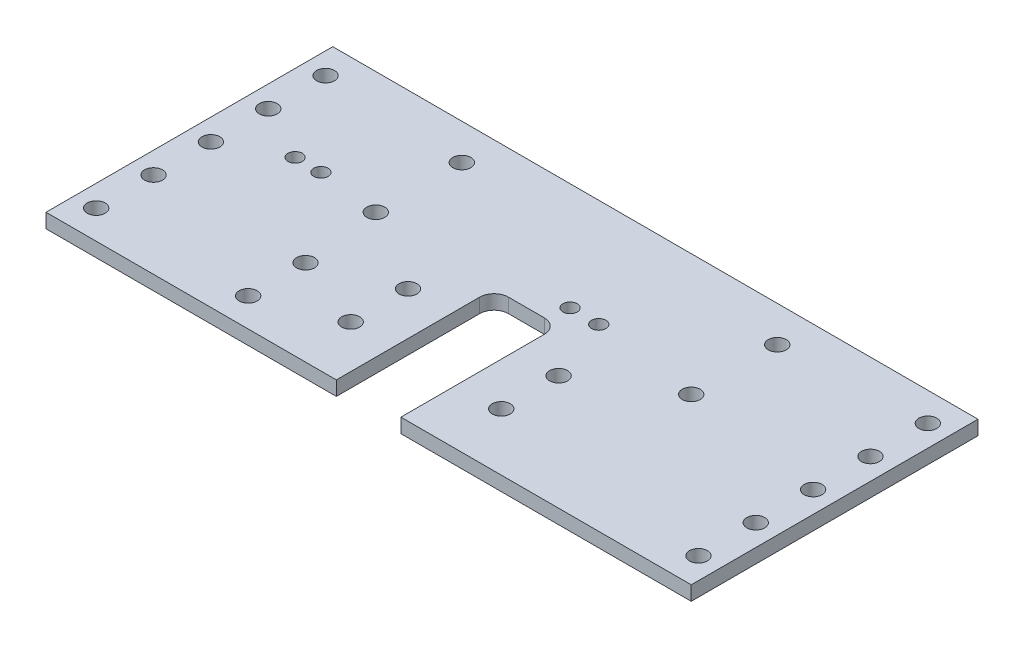
from build123d import *

# Parameters (mm, degrees)
SKETCH2_W            = 285.75
SKETCH2_H            = 6.35
STOCK_DEPTH          = 127
PEDAL_OPENINGS_DEPTH = 6.35
DRILLED_HOLES_REACH  = 8.35
SKETCH5_R            = 3.96875
SKETCH5_R_2          = 3.175


with BuildPart() as part:
    # Sketch2 → Stock (new body)
    with BuildSketch(Plane.XY):
        with Locations((-646.021194965, 51.468778461)):
            Rectangle(SKETCH2_W, SKETCH2_H)
    extrude(amount=-STOCK_DEPTH)

    # Sketch3 → Pedal Openings (cut)
    with BuildSketch(Plane(origin=(0, 54.643778461, 0), x_dir=(1, 0, 0), z_dir=(0, 1, 0))):
        with BuildLine():
            Line((-638.083694965, 69.85), (-653.958694965, 69.85))
            ThreePointArc((-653.958694965, 69.85), (-658.448823025, 67.990128061), (-660.308694965, 63.5))
            Line((-660.308694965, 63.5), (-660.308694965, 0))
            Line((-660.308694965, 0), (-631.733694965, 0))
            Line((-631.733694965, 0), (-631.733694965, 63.5))
            ThreePointArc((-631.733694965, 63.5), (-633.593566904, 67.990128061), (-638.083694965, 69.85))
        make_face()
    extrude(amount=-PEDAL_OPENINGS_DEPTH, mode=Mode.SUBTRACT)

    # Sketch5 → Drilled Holes (cut, up to next)
    with BuildSketch(Plane(origin=(0, 54.643778461, 0), x_dir=(1, 0, 0), z_dir=(0, 1, 0)), mode=Mode.PRIVATE) as drilled_holes_sk1:
        with Locations((-612.683694965, 25.4)):
            Circle(SKETCH5_R)
    drilled_holes_tool1 = extrude(drilled_holes_sk1.sketch, amount=-DRILLED_HOLES_REACH, mode=Mode.PRIVATE) & part.part
    add(drilled_holes_tool1.solids().sort_by_distance((-612.683695, 54.643778, -25.4))[0], mode=Mode.SUBTRACT)
    # Sketch5 → Drilled Holes (cut, up to next)
    with BuildSketch(Plane(origin=(0, 54.643778461, 0), x_dir=(1, 0, 0), z_dir=(0, 1, 0)), mode=Mode.PRIVATE) as drilled_holes_sk2:
        with Locations((-612.683694965, 50.8)):
            Circle(SKETCH5_R)
    drilled_holes_tool2 = extrude(drilled_holes_sk2.sketch, amount=-DRILLED_HOLES_REACH, mode=Mode.PRIVATE) & part.part
    add(drilled_holes_tool2.solids().sort_by_distance((-612.683695, 54.643778, -50.8))[0], mode=Mode.SUBTRACT)
    # Sketch5 → Drilled Holes (cut, up to next)
    with BuildSketch(Plane(origin=(0, 54.643778461, 0), x_dir=(1, 0, 0), z_dir=(0, 1, 0)), mode=Mode.PRIVATE) as drilled_holes_sk3:
        with Locations((-679.358694965, 50.8)):
            Circle(SKETCH5_R)
    drilled_holes_tool3 = extrude(drilled_holes_sk3.sketch, amount=-DRILLED_HOLES_REACH, mode=Mode.PRIVATE) & part.part
    add(drilled_holes_tool3.solids().sort_by_distance((-679.358695, 54.643778, -50.8))[0], mode=Mode.SUBTRACT)
    # Sketch5 → Drilled Holes (cut, up to next)
    with BuildSketch(Plane(origin=(0, 54.643778461, 0), x_dir=(1, 0, 0), z_dir=(0, 1, 0)), mode=Mode.PRIVATE) as drilled_holes_sk4:
        with Locations((-679.358694965, 25.4)):
            Circle(SKETCH5_R)
    drilled_holes_tool4 = extrude(drilled_holes_sk4.sketch, amount=-DRILLED_HOLES_REACH, mode=Mode.PRIVATE) & part.part
    add(drilled_holes_tool4.solids().sort_by_distance((-679.358695, 54.643778, -25.4))[0], mode=Mode.SUBTRACT)
    # Sketch5 → Drilled Holes (cut, up to next)
    with BuildSketch(Plane(origin=(0, 54.643778461, 0), x_dir=(1, 0, 0), z_dir=(0, 1, 0)), mode=Mode.PRIVATE) as drilled_holes_sk5:
        with Locations((-712.061194965, 12.7)):
            Circle(SKETCH5_R)
    drilled_holes_tool5 = extrude(drilled_holes_sk5.sketch, amount=-DRILLED_HOLES_REACH, mode=Mode.PRIVATE) & part.part
    add(drilled_holes_tool5.solids().sort_by_distance((-712.061195, 54.643778, -12.7))[0], mode=Mode.SUBTRACT)
    # Sketch5 → Drilled Holes (cut, up to next)
    with BuildSketch(Plane(origin=(0, 54.643778461, 0), x_dir=(1, 0, 0), z_dir=(0, 1, 0)), mode=Mode.PRIVATE) as drilled_holes_sk6:
        with Locations((-712.061194965, 38.1)):
            Circle(SKETCH5_R)
    drilled_holes_tool6 = extrude(drilled_holes_sk6.sketch, amount=-DRILLED_HOLES_REACH, mode=Mode.PRIVATE) & part.part
    add(drilled_holes_tool6.solids().sort_by_distance((-712.061195, 54.643778, -38.1))[0], mode=Mode.SUBTRACT)
    # Sketch5 → Drilled Holes (cut, up to next)
    with BuildSketch(Plane(origin=(0, 54.643778461, 0), x_dir=(1, 0, 0), z_dir=(0, 1, 0)), mode=Mode.PRIVATE) as drilled_holes_sk7:
        with Locations((-512.671194965, 12.7)):
            Circle(SKETCH5_R)
    drilled_holes_tool7 = extrude(drilled_holes_sk7.sketch, amount=-DRILLED_HOLES_REACH, mode=Mode.PRIVATE) & part.part
    add(drilled_holes_tool7.solids().sort_by_distance((-512.671195, 54.643778, -12.7))[0], mode=Mode.SUBTRACT)
    # Sketch5 → Drilled Holes (cut, up to next)
    with BuildSketch(Plane(origin=(0, 54.643778461, 0), x_dir=(1, 0, 0), z_dir=(0, 1, 0)), mode=Mode.PRIVATE) as drilled_holes_sk8:
        with Locations((-512.671194965, 38.1)):
            Circle(SKETCH5_R)
    drilled_holes_tool8 = extrude(drilled_holes_sk8.sketch, amount=-DRILLED_HOLES_REACH, mode=Mode.PRIVATE) & part.part
    add(drilled_holes_tool8.solids().sort_by_distance((-512.671195, 54.643778, -38.1))[0], mode=Mode.SUBTRACT)
    # Sketch5 → Drilled Holes (cut, up to next)
    with BuildSketch(Plane(origin=(0, 54.643778461, 0), x_dir=(1, 0, 0), z_dir=(0, 1, 0)), mode=Mode.PRIVATE) as drilled_holes_sk9:
        with Locations((-512.671194965, 63.5)):
            Circle(SKETCH5_R)
    drilled_holes_tool9 = extrude(drilled_holes_sk9.sketch, amount=-DRILLED_HOLES_REACH, mode=Mode.PRIVATE) & part.part
    add(drilled_holes_tool9.solids().sort_by_distance((-512.671195, 54.643778, -63.5))[0], mode=Mode.SUBTRACT)
    # Sketch5 → Drilled Holes (cut, up to next)
    with BuildSketch(Plane(origin=(0, 54.643778461, 0), x_dir=(1, 0, 0), z_dir=(0, 1, 0)), mode=Mode.PRIVATE) as drilled_holes_sk10:
        with Locations((-512.671194965, 88.9)):
            Circle(SKETCH5_R)
    drilled_holes_tool10 = extrude(drilled_holes_sk10.sketch, amount=-DRILLED_HOLES_REACH, mode=Mode.PRIVATE) & part.part
    add(drilled_holes_tool10.solids().sort_by_distance((-512.671195, 54.643778, -88.9))[0], mode=Mode.SUBTRACT)
    # Sketch5 → Drilled Holes (cut, up to next)
    with BuildSketch(Plane(origin=(0, 54.643778461, 0), x_dir=(1, 0, 0), z_dir=(0, 1, 0)), mode=Mode.PRIVATE) as drilled_holes_sk11:
        with Locations((-512.671194965, 114.3)):
            Circle(SKETCH5_R)
    drilled_holes_tool11 = extrude(drilled_holes_sk11.sketch, amount=-DRILLED_HOLES_REACH, mode=Mode.PRIVATE) & part.part
    add(drilled_holes_tool11.solids().sort_by_distance((-512.671195, 54.643778, -114.3))[0], mode=Mode.SUBTRACT)
    # Sketch5 → Drilled Holes (cut, up to next)
    with BuildSketch(Plane(origin=(0, 54.643778461, 0), x_dir=(1, 0, 0), z_dir=(0, 1, 0)), mode=Mode.PRIVATE) as drilled_holes_sk12:
        with Locations((-779.371194965, 88.9)):
            Circle(SKETCH5_R)
    drilled_holes_tool12 = extrude(drilled_holes_sk12.sketch, amount=-DRILLED_HOLES_REACH, mode=Mode.PRIVATE) & part.part
    add(drilled_holes_tool12.solids().sort_by_distance((-779.371195, 54.643778, -88.9))[0], mode=Mode.SUBTRACT)
    # Sketch5 → Drilled Holes (cut, up to next)
    with BuildSketch(Plane(origin=(0, 54.643778461, 0), x_dir=(1, 0, 0), z_dir=(0, 1, 0)), mode=Mode.PRIVATE) as drilled_holes_sk13:
        with Locations((-779.371194965, 114.3)):
            Circle(SKETCH5_R)
    drilled_holes_tool13 = extrude(drilled_holes_sk13.sketch, amount=-DRILLED_HOLES_REACH, mode=Mode.PRIVATE) & part.part
    add(drilled_holes_tool13.solids().sort_by_distance((-779.371195, 54.643778, -114.3))[0], mode=Mode.SUBTRACT)
    # Sketch5 → Drilled Holes (cut, up to next)
    with BuildSketch(Plane(origin=(0, 54.643778461, 0), x_dir=(1, 0, 0), z_dir=(0, 1, 0)), mode=Mode.PRIVATE) as drilled_holes_sk14:
        with Locations((-779.371194965, 63.5)):
            Circle(SKETCH5_R)
    drilled_holes_tool14 = extrude(drilled_holes_sk14.sketch, amount=-DRILLED_HOLES_REACH, mode=Mode.PRIVATE) & part.part
    add(drilled_holes_tool14.solids().sort_by_distance((-779.371195, 54.643778, -63.5))[0], mode=Mode.SUBTRACT)
    # Sketch5 → Drilled Holes (cut, up to next)
    with BuildSketch(Plane(origin=(0, 54.643778461, 0), x_dir=(1, 0, 0), z_dir=(0, 1, 0)), mode=Mode.PRIVATE) as drilled_holes_sk15:
        with Locations((-779.371194965, 38.1)):
            Circle(SKETCH5_R)
    drilled_holes_tool15 = extrude(drilled_holes_sk15.sketch, amount=-DRILLED_HOLES_REACH, mode=Mode.PRIVATE) & part.part
    add(drilled_holes_tool15.solids().sort_by_distance((-779.371195, 54.643778, -38.1))[0], mode=Mode.SUBTRACT)
    # Sketch5 → Drilled Holes (cut, up to next)
    with BuildSketch(Plane(origin=(0, 54.643778461, 0), x_dir=(1, 0, 0), z_dir=(0, 1, 0)), mode=Mode.PRIVATE) as drilled_holes_sk16:
        with Locations((-779.371194965, 12.7)):
            Circle(SKETCH5_R)
    drilled_holes_tool16 = extrude(drilled_holes_sk16.sketch, amount=-DRILLED_HOLES_REACH, mode=Mode.PRIVATE) & part.part
    add(drilled_holes_tool16.solids().sort_by_distance((-779.371195, 54.643778, -12.7))[0], mode=Mode.SUBTRACT)
    # Sketch5 → Drilled Holes (cut, up to next)
    with BuildSketch(Plane(origin=(0, 54.643778461, 0), x_dir=(1, 0, 0), z_dir=(0, 1, 0)), mode=Mode.PRIVATE) as drilled_holes_sk17:
        with Locations((-576.171194965, 73.025)):
            Circle(SKETCH5_R)
    drilled_holes_tool17 = extrude(drilled_holes_sk17.sketch, amount=-DRILLED_HOLES_REACH, mode=Mode.PRIVATE) & part.part
    add(drilled_holes_tool17.solids().sort_by_distance((-576.171195, 54.643778, -73.025))[0], mode=Mode.SUBTRACT)
    # Sketch5 → Drilled Holes (cut, up to next)
    with BuildSketch(Plane(origin=(0, 54.643778461, 0), x_dir=(1, 0, 0), z_dir=(0, 1, 0)), mode=Mode.PRIVATE) as drilled_holes_sk18:
        with Locations((-576.171194965, 111.125)):
            Circle(SKETCH5_R)
    drilled_holes_tool18 = extrude(drilled_holes_sk18.sketch, amount=-DRILLED_HOLES_REACH, mode=Mode.PRIVATE) & part.part
    add(drilled_holes_tool18.solids().sort_by_distance((-576.171195, 54.643778, -111.125))[0], mode=Mode.SUBTRACT)
    # Sketch5 → Drilled Holes (cut, up to next)
    with BuildSketch(Plane(origin=(0, 54.643778461, 0), x_dir=(1, 0, 0), z_dir=(0, 1, 0)), mode=Mode.PRIVATE) as drilled_holes_sk19:
        with Locations((-715.871194965, 111.125)):
            Circle(SKETCH5_R)
    drilled_holes_tool19 = extrude(drilled_holes_sk19.sketch, amount=-DRILLED_HOLES_REACH, mode=Mode.PRIVATE) & part.part
    add(drilled_holes_tool19.solids().sort_by_distance((-715.871195, 54.643778, -111.125))[0], mode=Mode.SUBTRACT)
    # Sketch5 → Drilled Holes (cut, up to next)
    with BuildSketch(Plane(origin=(0, 54.643778461, 0), x_dir=(1, 0, 0), z_dir=(0, 1, 0)), mode=Mode.PRIVATE) as drilled_holes_sk20:
        with Locations((-715.871194965, 73.025)):
            Circle(SKETCH5_R)
    drilled_holes_tool20 = extrude(drilled_holes_sk20.sketch, amount=-DRILLED_HOLES_REACH, mode=Mode.PRIVATE) & part.part
    add(drilled_holes_tool20.solids().sort_by_distance((-715.871195, 54.643778, -73.025))[0], mode=Mode.SUBTRACT)
    # Sketch5 → Drilled Holes (cut, up to next)
    with BuildSketch(Plane(origin=(0, 54.643778461, 0), x_dir=(1, 0, 0), z_dir=(0, 1, 0)), mode=Mode.PRIVATE) as drilled_holes_sk21:
        with Locations((-754.764944965, 76.2)):
            Circle(SKETCH5_R_2)
    drilled_holes_tool21 = extrude(drilled_holes_sk21.sketch, amount=-DRILLED_HOLES_REACH, mode=Mode.PRIVATE) & part.part
    add(drilled_holes_tool21.solids().sort_by_distance((-754.764945, 54.643778, -76.2))[0], mode=Mode.SUBTRACT)
    # Sketch5 → Drilled Holes (cut, up to next)
    with BuildSketch(Plane(origin=(0, 54.643778461, 0), x_dir=(1, 0, 0), z_dir=(0, 1, 0)), mode=Mode.PRIVATE) as drilled_holes_sk22:
        with Locations((-743.334944965, 76.2)):
            Circle(SKETCH5_R_2)
    drilled_holes_tool22 = extrude(drilled_holes_sk22.sketch, amount=-DRILLED_HOLES_REACH, mode=Mode.PRIVATE) & part.part
    add(drilled_holes_tool22.solids().sort_by_distance((-743.334945, 54.643778, -76.2))[0], mode=Mode.SUBTRACT)
    # Sketch5 → Drilled Holes (cut, up to next)
    with BuildSketch(Plane(origin=(0, 54.643778461, 0), x_dir=(1, 0, 0), z_dir=(0, 1, 0)), mode=Mode.PRIVATE) as drilled_holes_sk23:
        with Locations((-636.178694965, 79.375)):
            Circle(SKETCH5_R_2)
    drilled_holes_tool23 = extrude(drilled_holes_sk23.sketch, amount=-DRILLED_HOLES_REACH, mode=Mode.PRIVATE) & part.part
    add(drilled_holes_tool23.solids().sort_by_distance((-636.178695, 54.643778, -79.375))[0], mode=Mode.SUBTRACT)
    # Sketch5 → Drilled Holes (cut, up to next)
    with BuildSketch(Plane(origin=(0, 54.643778461, 0), x_dir=(1, 0, 0), z_dir=(0, 1, 0)), mode=Mode.PRIVATE) as drilled_holes_sk24:
        with Locations((-623.478694965, 79.375)):
            Circle(SKETCH5_R_2)
    drilled_holes_tool24 = extrude(drilled_holes_sk24.sketch, amount=-DRILLED_HOLES_REACH, mode=Mode.PRIVATE) & part.part
    add(drilled_holes_tool24.solids().sort_by_distance((-623.478695, 54.643778, -79.375))[0], mode=Mode.SUBTRACT)


solid = part.part
